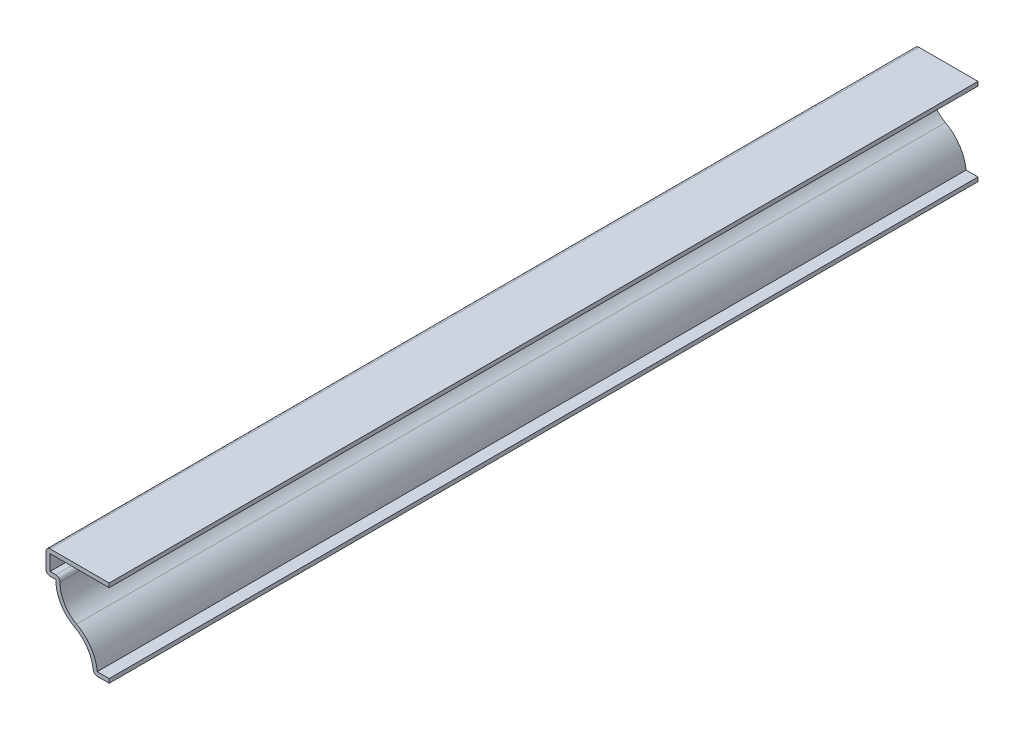
from build123d import *

# Parameters (mm, degrees)
EXTRUDE_THIN1_DEPTH = 349.25
FILLET1_R           = 1.651


with BuildPart() as part:
    # Sketch1 → Extrude-Thin1 (new body)
    with BuildSketch(Plane.XY):
        with BuildLine():
            Line((0, 34.925), (-25.4, 34.925))
            Line((-25.4, 34.925), (-25.4, 25.4))
            Line((-25.4, 25.4), (-21.43125, 25.4))
            ThreePointArc((-21.43125, 25.4), (-19.457151595, 17.939895967), (-13.891403239, 12.594555758))
            ThreePointArc((-13.891403239, 12.594555758), (-8.379492133, 7.339884154), (-6.35, 0))
            Line((-6.35, 0), (0, 0))
            Line((0, 0), (0, 1.651))
            Line((0, 1.651), (-4.784740579, 1.651))
            ThreePointArc((-4.784740579, 1.651), (-7.406067643, 8.886224172), (-13.11185428, 14.049926646))
            ThreePointArc((-13.11185428, 14.049926646), (-18.436772895, 19.516024313), (-19.643886539, 27.051))
            Line((-19.643886539, 27.051), (-23.749, 27.051))
            Line((-23.749, 27.051), (-23.749, 33.274))
            Line((-23.749, 33.274), (0, 33.274))
            Line((0, 33.274), (0, 34.925))
        make_face()
    extrude(amount=-EXTRUDE_THIN1_DEPTH)

    # Fillet1
    fillet1_edges = [part.edges().sort_by_distance(p)[0] for p in [
        (-6.35, 0, -174.625),
        (-25.4, 25.4, -174.625),
        (-25.4, 34.925, -174.625),
        (-19.643886539, 27.051, -174.625),
    ]]
    fillet(fillet1_edges, radius=FILLET1_R)


solid = part.part
